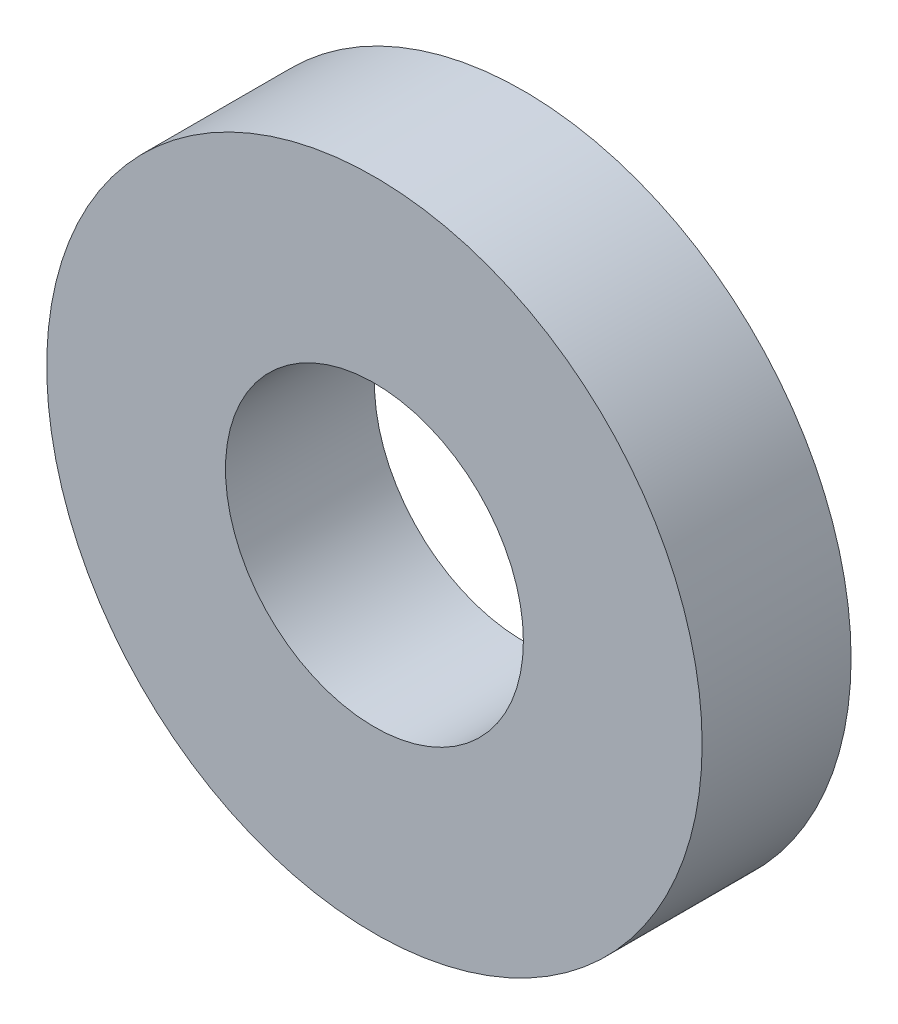
from build123d import *

# Parameters (mm, degrees)
SKETCH1_R           = 13.2
SKETCH1_R_2         = 6
BOSS_EXTRUDE1_DEPTH = 6
CUT_EXTRUDE1_DEPTH  = 2.54
SKETCH3_R           = 13.2
SKETCH3_R_2         = 6
BOSS_EXTRUDE2_DEPTH = 6


with BuildPart() as part:
    # Sketch1 → Boss-Extrude1 (new body)
    with BuildSketch(Plane.XY):
        Circle(SKETCH1_R)
        Circle(SKETCH1_R_2, mode=Mode.SUBTRACT)
    extrude(amount=BOSS_EXTRUDE1_DEPTH)

    # Sketch2 → Cut-Extrude1 (cut)
    with BuildSketch(Plane.XY.offset(6)):
        with BuildLine():
            ThreePointArc((-2.819851171, 12.895287487), (0, 13.2), (2.819851171, 12.895287487))
            ThreePointArc((2.819851171, 12.895287487), (1.826256171, 11.910750525), (1.819851171, 10.512))
            ThreePointArc((1.819851171, 10.512), (0, 10.668364555), (-1.819851171, 10.512))
            ThreePointArc((-1.819851171, 10.512), (-1.826256171, 11.910750525), (-2.819851171, 12.895287487))
        make_face()
    extrude(amount=-CUT_EXTRUDE1_DEPTH, mode=Mode.SUBTRACT)

    # Sketch3 → Boss-Extrude2 (add)
    with BuildSketch(Plane.XY):
        Circle(SKETCH3_R)
        Circle(SKETCH3_R_2, mode=Mode.SUBTRACT)
    extrude(amount=BOSS_EXTRUDE2_DEPTH)


solid = part.part
